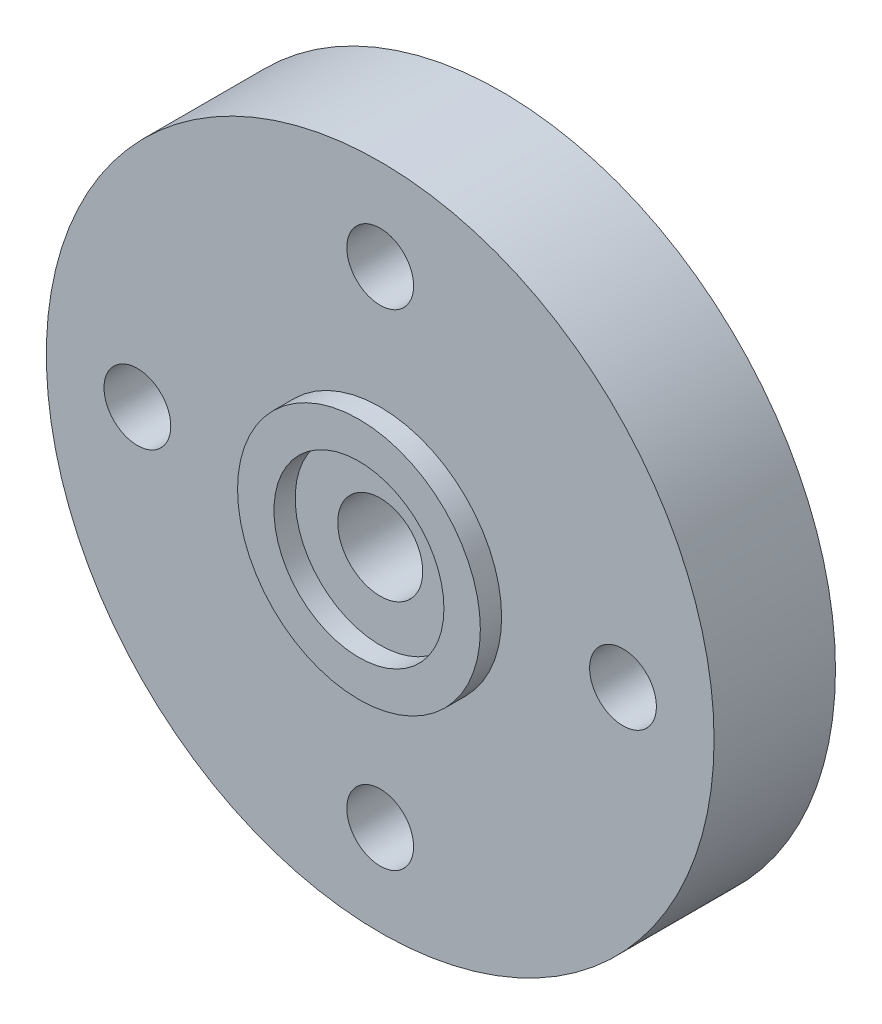
from build123d import *

# Parameters (mm, degrees)
ESQUISSE1_R      = 11
ESQUISSE1_R_2    = 1.1
EXTRUSION1_DEPTH = 4
ESQUISSE2_R      = 4
ESQUISSE2_R_2    = 2.8
EXTRUSION3_DEPTH = 0.7
EXTRUSION4_REACH = 6
ESQUISSE3_R      = 1.4


with BuildPart() as part:
    # Esquisse1 → Extrusion1 (new body)
    with BuildSketch(Plane.XY):
        Circle(ESQUISSE1_R)
        with Locations((0, 8)):
            Circle(ESQUISSE1_R_2, mode=Mode.SUBTRACT)
        with Locations((-8, 0)):
            Circle(ESQUISSE1_R_2, mode=Mode.SUBTRACT)
        with Locations((8, 0)):
            Circle(ESQUISSE1_R_2, mode=Mode.SUBTRACT)
        with Locations((0, -8)):
            Circle(ESQUISSE1_R_2, mode=Mode.SUBTRACT)
    extrude(amount=EXTRUSION1_DEPTH)

    # Esquisse2 → Extrusion3 (add)
    with BuildSketch(Plane.XY.offset(4)):
        Circle(ESQUISSE2_R)
        Circle(ESQUISSE2_R_2, mode=Mode.SUBTRACT)
    extrude(amount=EXTRUSION3_DEPTH)

    # Esquisse3 → Extrusion4 (cut, up to next)
    with BuildSketch(Plane.XY.offset(4), mode=Mode.PRIVATE) as extrusion4_sk1:
        Circle(ESQUISSE3_R)
    extrusion4_tool1 = extrude(extrusion4_sk1.sketch, amount=-EXTRUSION4_REACH, mode=Mode.PRIVATE) & part.part
    add(extrusion4_tool1.solids().sort_by_distance((0, 0, 4))[0], mode=Mode.SUBTRACT)


solid = part.part
